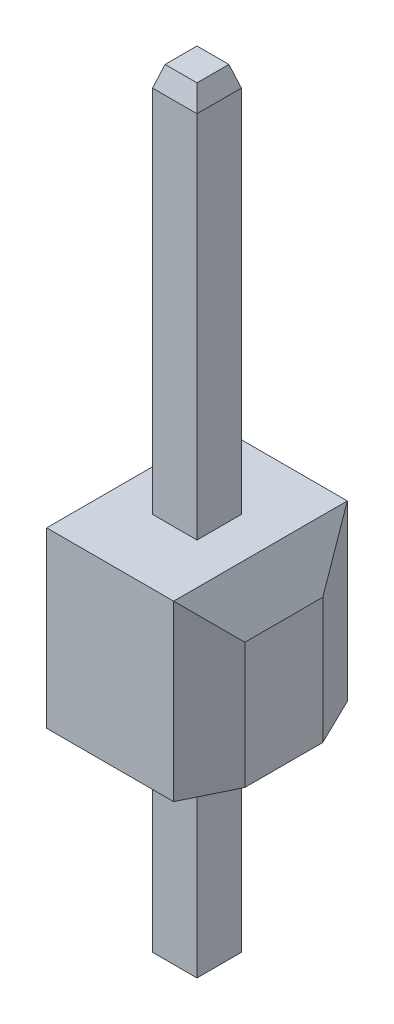
from build123d import *

# Parameters (mm, degrees)
SKETCH1_W                = 2.54
SKETCH1_H                = 2.54
BOSS_EXTRUDE1_DEPTH      = 2.54
SKETCH2_W                = 0.65
SKETCH2_H                = 0.65
BOSS_EXTRUDE2_DEPTH      = 5.7
BOSS_EXTRUDE2_DEPTH_BACK = 5.64
CHAMFER1_SIZE            = 0.3
CHAMFER1_SIZE2           = 0.091719204
CHAMFER1_PART_2_SIZE     = 0.3
CHAMFER1_PART_2_SIZE2    = 0.091719204
CHAMFER1_PART_3_SIZE     = 0.3
CHAMFER1_PART_3_SIZE2    = 0.091719204
CHAMFER1_PART_4_SIZE     = 0.3
CHAMFER1_PART_4_SIZE2    = 0.091719204
CHAMFER1_PART_5_SIZE     = 0.3
CHAMFER1_PART_5_SIZE2    = 0.091719204
CHAMFER3_SIZE            = 0.7
CHAMFER3_SIZE2           = 0.341412812
CHAMFER4_SIZE            = 0.7
CHAMFER4_SIZE2           = 0.341412812


with BuildPart() as part:
    # Sketch1 → Boss-Extrude1 (new body)
    with BuildSketch(Plane(origin=(0, 0, 0), x_dir=(1, 0, 0), z_dir=(0, 1, 0))):
        Rectangle(SKETCH1_W, SKETCH1_H)
    extrude(amount=BOSS_EXTRUDE1_DEPTH)

    # Sketch2 → Boss-Extrude2 (add, two sides)
    with BuildSketch(Plane(origin=(0, 2.54, 0), x_dir=(1, 0, 0), z_dir=(0, 1, 0))) as boss_extrude2_sk:
        Rectangle(SKETCH2_W, SKETCH2_H)
    extrude(amount=BOSS_EXTRUDE2_DEPTH)
    extrude(boss_extrude2_sk.sketch, amount=-BOSS_EXTRUDE2_DEPTH_BACK)

    # Chamfer1
    chamfer1_edges = [part.edges().sort_by_distance(p)[0] for p in [
        (-0.325, -3.1, 0),
        (0, -3.1, -0.325),
        (0.325, -3.1, 0),
        (0, -3.1, 0.325),
    ]]
    chamfer1_side = [part.faces().sort_by_distance(p)[0] for p in [
        (0, -3.1, 0),
    ]]
    chamfer(chamfer1_edges, length=CHAMFER1_SIZE, length2=CHAMFER1_SIZE2, reference=chamfer1_side[0])

    # Chamfer1 part 2
    chamfer1_part_2_edges = [part.edges().sort_by_distance(p)[0] for p in [
        (-0.325, 8.24, 0),
    ]]
    chamfer1_part_2_side = [part.faces().sort_by_distance(p)[0] for p in [
        (-0.325, 5.39, 0),
    ]]
    chamfer(chamfer1_part_2_edges, length=CHAMFER1_PART_2_SIZE, length2=CHAMFER1_PART_2_SIZE2, reference=chamfer1_part_2_side[0])

    # Chamfer1 part 3
    chamfer1_part_3_edges = [part.edges().sort_by_distance(p)[0] for p in [
        (0, 8.24, 0.325),
    ]]
    chamfer1_part_3_side = [part.faces().sort_by_distance(p)[0] for p in [
        (0, 5.39, 0.325),
    ]]
    chamfer(chamfer1_part_3_edges, length=CHAMFER1_PART_3_SIZE, length2=CHAMFER1_PART_3_SIZE2, reference=chamfer1_part_3_side[0])

    # Chamfer1 part 4
    chamfer1_part_4_edges = [part.edges().sort_by_distance(p)[0] for p in [
        (0.325, 8.24, 0),
    ]]
    chamfer1_part_4_side = [part.faces().sort_by_distance(p)[0] for p in [
        (0.325, 5.39, 0),
    ]]
    chamfer(chamfer1_part_4_edges, length=CHAMFER1_PART_4_SIZE, length2=CHAMFER1_PART_4_SIZE2, reference=chamfer1_part_4_side[0])

    # Chamfer1 part 5
    chamfer1_part_5_edges = [part.edges().sort_by_distance(p)[0] for p in [
        (0, 8.24, -0.325),
    ]]
    chamfer1_part_5_side = [part.faces().sort_by_distance(p)[0] for p in [
        (0, 5.39, -0.325),
    ]]
    chamfer(chamfer1_part_5_edges, length=CHAMFER1_PART_5_SIZE, length2=CHAMFER1_PART_5_SIZE2, reference=chamfer1_part_5_side[0])

    # Chamfer3
    chamfer3_edges = [part.edges().sort_by_distance(p)[0] for p in [
        (1.27, 2.54, 0),
        (1.27, 1.27, 1.27),
        (1.27, 1.27, -1.27),
    ]]
    chamfer3_side = [part.faces().sort_by_distance(p)[0] for p in [
        (1.27, 1.27, 0),
    ]]
    chamfer(chamfer3_edges, length=CHAMFER3_SIZE, length2=CHAMFER3_SIZE2, reference=chamfer3_side[0])

    # Chamfer4
    chamfer4_edges = [part.edges().sort_by_distance(p)[0] for p in [
        (-1.27, 2.54, 0),
        (-1.27, 1.27, 1.27),
        (-1.27, 1.27, -1.27),
    ]]
    chamfer4_side = [part.faces().sort_by_distance(p)[0] for p in [
        (-1.27, 1.27, 0),
    ]]
    chamfer(chamfer4_edges, length=CHAMFER4_SIZE, length2=CHAMFER4_SIZE2, reference=chamfer4_side[0])


solid = part.part
